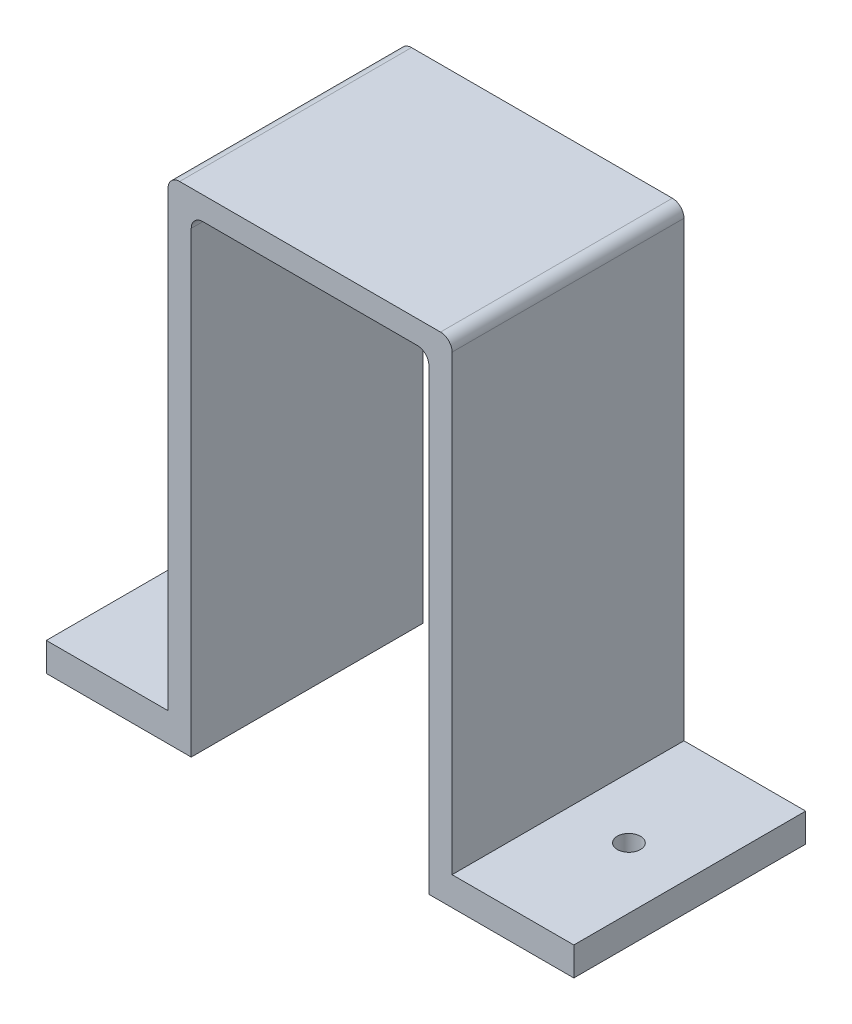
from build123d import *

# Parameters (mm, degrees)
BOSS_EXTRUDE1_DEPTH = 20
FILLET1_R           = 1
SKETCH2_R           = 1
CUT_EXTRUDE1_DEPTH  = 20


with BuildPart() as part:
    # Sketch1 → Boss-Extrude1 (new body)
    with BuildSketch(Plane.XY):
        Polygon((-22.5, -10.265235457), (-22.5, 30.234764543), (-2, 30.234764543), (-2, -10.265235457), (0, -10.265235457), (10.5, -10.265235457), (10.5, -7.797091413), (0, -7.797091413), (0, 32.234764543), (-24.5, 32.234764543), (-24.5, -7.797091413), (-35, -7.797091413), (-35, -10.265235457), (-26.067867036, -10.265235457), align=None)
    extrude(amount=BOSS_EXTRUDE1_DEPTH)

    # Fillet1
    fillet1_edges = [part.edges().sort_by_distance(p)[0] for p in [
        (-22.5, 30.234764543, 10),
        (-2, 30.234764543, 10),
        (0, 32.234764543, 10),
        (-24.5, 32.234764543, 10),
    ]]
    fillet(fillet1_edges, radius=FILLET1_R)

    # Sketch2 → Cut-Extrude1 (cut)
    with BuildSketch(Plane(origin=(0, -7.797091413, 0), x_dir=(1, 0, 0), z_dir=(0, 1, 0))):
        with Locations((-29.75, -10)):
            Circle(SKETCH2_R)
        with Locations((5.25, -10)):
            Circle(SKETCH2_R)
    extrude(amount=-CUT_EXTRUDE1_DEPTH, mode=Mode.SUBTRACT)


solid = part.part
